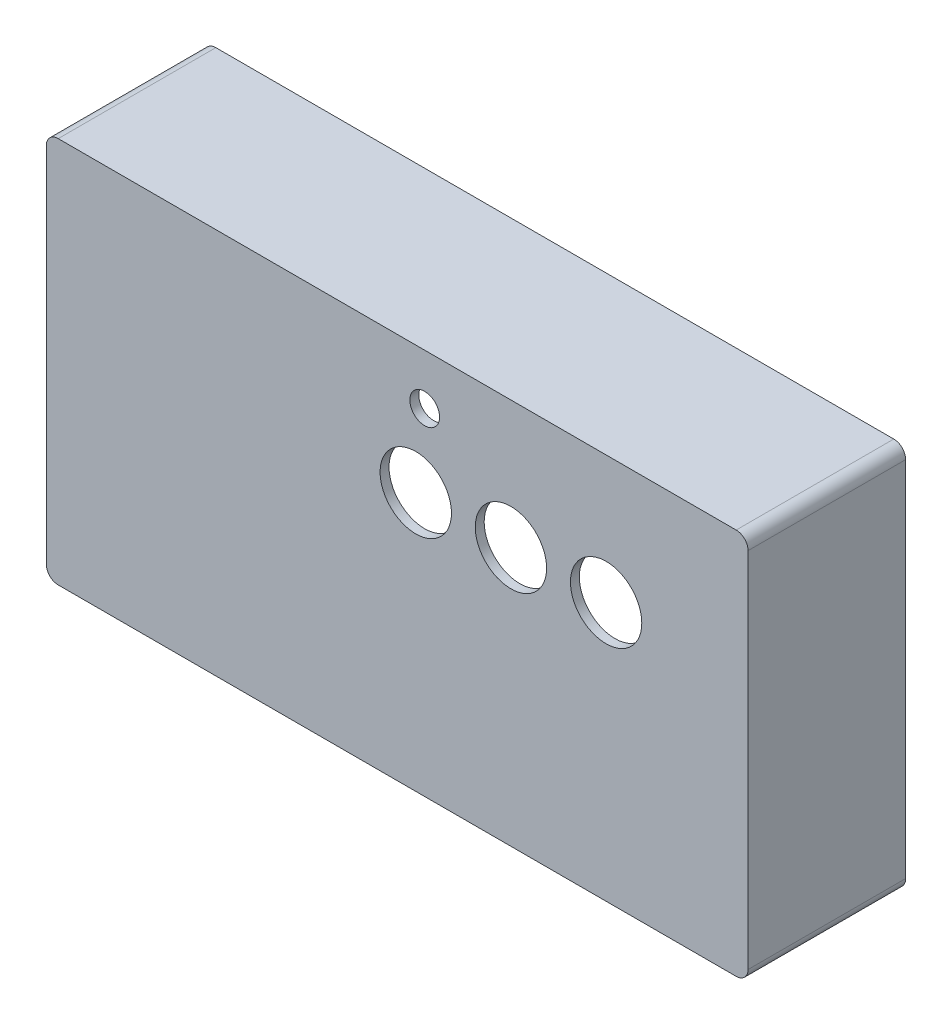
from build123d import *

# Parameters (mm, degrees)
SKETCH2_W           = 118
SKETCH2_H           = 65
BOSS_EXTRUDE2_DEPTH = 1.5
SKETCH4_W           = 118
SKETCH4_H           = 65
SKETCH4_W_2         = 114
SKETCH4_H_2         = 61
BOSS_EXTRUDE3_DEPTH = 25
FILLET2_R           = 2
FILLET3_R           = 1
SKETCH5_R           = 6
SKETCH5_R_2         = 2.5
CUT_EXTRUDE1_DEPTH  = 27.5
SKETCH6_R           = 1
SKETCH6_W           = 7
SKETCH6_H           = 3
BOSS_EXTRUDE4_DEPTH = 8
FILLET4_R           = 2
FILLET6_R           = 2


with BuildPart() as part:
    # Sketch2 → Boss-Extrude2 (new body)
    with BuildSketch(Plane.XY):
        Rectangle(SKETCH2_W, SKETCH2_H)
    extrude(amount=BOSS_EXTRUDE2_DEPTH)

    # Sketch4 → Boss-Extrude3 (add)
    with BuildSketch(Plane.XY):
        Rectangle(SKETCH4_W, SKETCH4_H)
        Rectangle(SKETCH4_W_2, SKETCH4_H_2, mode=Mode.SUBTRACT)
    extrude(amount=-BOSS_EXTRUDE3_DEPTH)

    # Fillet2
    fillet2_edges = [part.edges().sort_by_distance(p)[0] for p in [
        (59, 32.5, -11.75),
        (59, -32.5, -11.75),
        (-59, -32.5, -11.75),
        (-59, 32.5, -11.75),
    ]]
    fillet(fillet2_edges, radius=FILLET2_R)

    # Fillet3
    fillet3_edges = [part.edges().sort_by_distance(p)[0] for p in [
        (-57, -30.5, -12.5),
        (-57, 30.5, -12.5),
        (57, 30.5, -12.5),
        (57, -30.5, -12.5),
    ]]
    fillet(fillet3_edges, radius=FILLET3_R)

    # Sketch5 → Cut-Extrude1 (cut, through all)
    with BuildSketch(Plane.XY.offset(1.5)):
        with Locations((35.125, 11)):
            Circle(SKETCH5_R)
        with Locations((19.125, 11)):
            Circle(SKETCH5_R)
        with Locations((3.125, 11)):
            Circle(SKETCH5_R)
        with Locations((4.625, 24)):
            Circle(SKETCH5_R_2)
    extrude(amount=-CUT_EXTRUDE1_DEPTH, mode=Mode.SUBTRACT)

    # Sketch6 → Boss-Extrude4 (add)
    with BuildSketch(Plane(origin=(0, 0, 0), x_dir=(-1, 0, 0), z_dir=(0, 0, -1))):
        with BuildLine():
            Line((-57, 30.5), (-57, 23))
            Line((-57, 23), (-52.125, 23))
            ThreePointArc((-52.125, 23), (-50.003679656, 23.878679656), (-49.125, 26))
            Line((-49.125, 26), (-49.125, 30.5))
            Line((-49.125, 30.5), (-57, 30.5))
        make_face()
        with Locations((-52.125, 26)):
            Circle(SKETCH6_R, mode=Mode.SUBTRACT)
        with BuildLine():
            Line((32.875, 30.5), (38.875, 30.5))
            Line((38.875, 30.5), (38.875, 26))
            ThreePointArc((38.875, 26), (35.875, 23), (32.875, 26))
            Line((32.875, 26), (32.875, 30.5))
        make_face()
        with Locations((35.875, 26)):
            Circle(SKETCH6_R, mode=Mode.SUBTRACT)
        with Locations((-3.125, 29)):
            Rectangle(SKETCH6_W, SKETCH6_H)
    boss_extrude4 = extrude(amount=BOSS_EXTRUDE4_DEPTH)

    # Mirror1: Boss-Extrude4 across plane
    add(boss_extrude4.mirror(Plane.ZX))

    # Fillet4
    fillet4_edges = [part.edges().sort_by_distance(p)[0] for p in [
        (49.125, 30.5, -4),
        (57, 23, -4),
        (-32.875, 30.5, -4),
        (-38.875, 30.5, -4),
        (-0.375, 30.5, -4),
        (6.625, 30.5, -4),
        (57, -23, -4),
        (49.125, -30.5, -4),
        (-32.875, -30.5, -4),
        (-38.875, -30.5, -4),
        (-0.375, -30.5, -4),
        (6.625, -30.5, -4),
    ]]
    fillet(fillet4_edges, radius=FILLET4_R)

    # Fillet6
    fillet6_edges = [part.edges().sort_by_distance(p)[0] for p in [
        (-0.375, 27.5, -4),
        (6.625, 27.5, -4),
        (6.625, -27.5, -4),
        (-0.375, -27.5, -4),
    ]]
    fillet(fillet6_edges, radius=FILLET6_R)


solid = part.part
